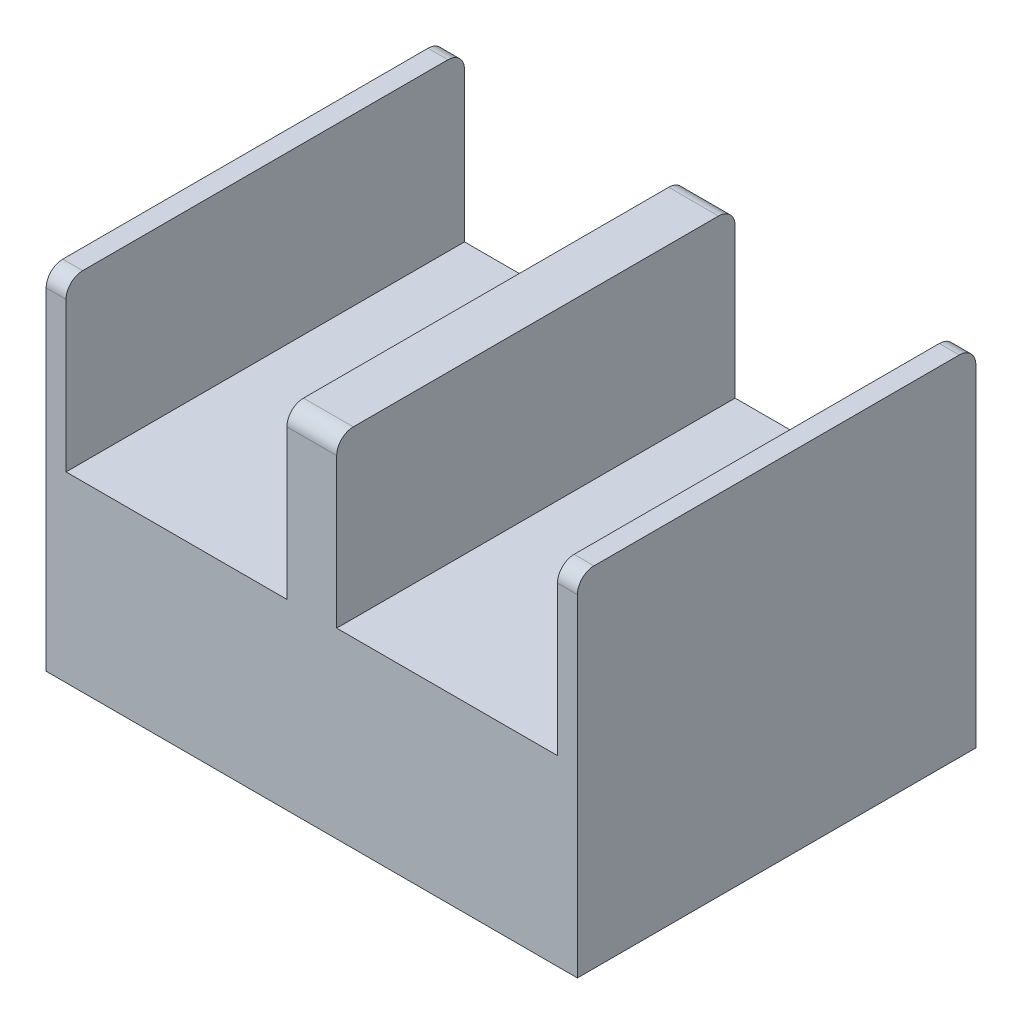
from build123d import *

# Parameters (mm, degrees)
SKETCH1_W             = 16
SKETCH1_H             = 12
BOSS_EXTRUDE1_DEPTH   = 5.5
SKETCH2_W             = 0.6
SKETCH2_H             = 12
SKETCH2_W_2           = 1.5
BOSS_EXTRUDE2_DEPTH   = 5
FILLET1_R             = 0.5
M3_TAPPED_HOLE1_D     = 2.5
M3_TAPPED_HOLE1_DEPTH = 10
M3_TAPPED_HOLE1_TIP   = 0.751075774


with BuildPart() as part:
    # Sketch1 → Boss-Extrude1 (new body)
    with BuildSketch(Plane(origin=(0, 0, 0), x_dir=(1, 0, 0), z_dir=(0, 1, 0))):
        Rectangle(SKETCH1_W, SKETCH1_H)
    extrude(amount=BOSS_EXTRUDE1_DEPTH)

    # Sketch2 → Boss-Extrude2 (add)
    with BuildSketch(Plane(origin=(0, 5.5, 0), x_dir=(1, 0, 0), z_dir=(0, 1, 0))):
        with Locations((-7.7, 0)):
            Rectangle(SKETCH2_W, SKETCH2_H)
        with Locations((7.7, 0)):
            Rectangle(SKETCH2_W, SKETCH2_H)
        Rectangle(SKETCH2_W_2, SKETCH2_H)
    extrude(amount=BOSS_EXTRUDE2_DEPTH)

    # Fillet1
    fillet1_edges = [part.edges().sort_by_distance(p)[0] for p in [
        (-7.7, 10.5, 6),
        (-7.7, 10.5, -6),
        (7.7, 10.5, -6),
        (7.7, 10.5, 6),
        (0, 10.5, 6),
        (0, 10.5, -6),
    ]]
    fillet(fillet1_edges, radius=FILLET1_R)

    # M3 Tapped Hole1
    with Locations(Plane(origin=(0, 5.5, 0), x_dir=(1, 0, 0), z_dir=(0, 1, 0))):
        with Locations((-4.075, 0), (4.075, 0)):
            Hole(M3_TAPPED_HOLE1_D / 2, depth=M3_TAPPED_HOLE1_DEPTH)
            with Locations((0, 0, -(M3_TAPPED_HOLE1_DEPTH + M3_TAPPED_HOLE1_TIP / 2))):  # 118° drill point
                Cone(0, M3_TAPPED_HOLE1_D / 2, M3_TAPPED_HOLE1_TIP, mode=Mode.SUBTRACT)


solid = part.part
